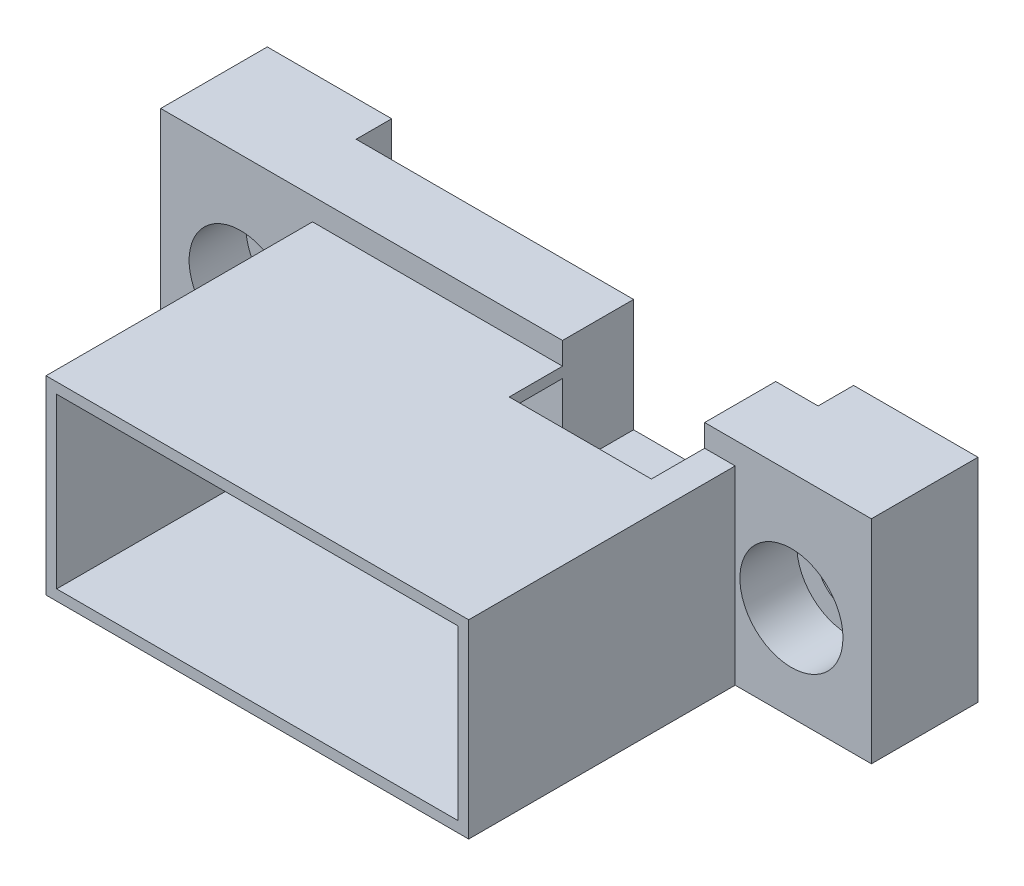
from build123d import *

# Parameters (mm, degrees)
SKETCH4_W               = 50.8
SKETCH4_H               = 16.764
BOSS_EXTRUDE1_DEPTH     = 7.62
SKETCH5_R               = 0.8255
SKETCH5_W               = 10.16
SKETCH5_H               = 5.08
CUT_EXTRUDE1_DEPTH      = 7.62
SKETCH6_R               = 3.683
SKETCH6_R_2             = 2.2225
CUT_EXTRUDE2_DEPTH      = 4.064
SKETCH6_2_R             = 2.2225
CUT_EXTRUDE3_DEPTH      = 7.62
SKETCH7_W               = 33.02
SKETCH7_H               = 5.08
CUT_EXTRUDE4_DEPTH      = 1
CUT_EXTRUDE4_DEPTH_BACK = 17.764
SKETCH8_W               = 10.16
SKETCH8_H               = 2.54
CUT_EXTRUDE5_DEPTH      = 4.064
SKETCH9_W               = 30.2133
SKETCH9_H               = 13.5763
SKETCH9_W_2             = 28.6893
SKETCH9_H_2             = 12.0523
BOSS_EXTRUDE4_DEPTH     = 19.05
SKETCH12_W              = 10.16
SKETCH12_H              = 2.99085
CUT_EXTRUDE6_DEPTH      = 6.35
SKETCH13_W              = 50.8
SKETCH13_H              = 1.59385
CUT_EXTRUDE7_DEPTH      = 20.05
CUT_EXTRUDE7_DEPTH_BACK = 8.62


with BuildPart() as part:
    # Sketch4 → Boss-Extrude1 (new body)
    with BuildSketch(Plane.XY):
        Rectangle(SKETCH4_W, SKETCH4_H)
    extrude(amount=BOSS_EXTRUDE1_DEPTH)

    # Sketch5 → Cut-Extrude1 (cut)
    with BuildSketch(Plane.XY.offset(7.62)):
        with Locations((-11.24585, 3.48615)):
            Circle(SKETCH5_R)
        with Locations((12.36345, -3.48615)):
            Circle(SKETCH5_R)
        with Locations((8.40105, 2.85115)):
            Rectangle(SKETCH5_W, SKETCH5_H)
    extrude(amount=-CUT_EXTRUDE1_DEPTH, mode=Mode.SUBTRACT)

    # Sketch6 → Cut-Extrude2 (cut)
    with BuildSketch(Plane.XY.offset(7.62)):
        with Locations((-19.685, 0)):
            Circle(SKETCH6_R)
        with Locations((-19.685, 0)):
            Circle(SKETCH6_R_2, mode=Mode.SUBTRACT)
        with Locations((19.685, 0)):
            Circle(SKETCH6_R)
        with Locations((19.685, 0)):
            Circle(SKETCH6_R_2, mode=Mode.SUBTRACT)
    extrude(amount=-CUT_EXTRUDE2_DEPTH, mode=Mode.SUBTRACT)

    # Sketch6_2 → Cut-Extrude3 (cut)
    with BuildSketch(Plane.XY.offset(7.62)):
        with Locations((-19.685, 0)):
            Circle(SKETCH6_2_R)
        with Locations((19.685, 0)):
            Circle(SKETCH6_2_R)
    extrude(amount=-CUT_EXTRUDE3_DEPTH, mode=Mode.SUBTRACT)

    # Sketch7 → Cut-Extrude4 (cut, two sides)
    with BuildSketch(Plane(origin=(0, 8.382, 0), x_dir=(1, 0, 0), z_dir=(0, 1, 0))) as cut_extrude4_sk:
        Rectangle(SKETCH7_W, SKETCH7_H)
    extrude(amount=CUT_EXTRUDE4_DEPTH, mode=Mode.SUBTRACT)
    extrude(cut_extrude4_sk.sketch, amount=-CUT_EXTRUDE4_DEPTH_BACK, mode=Mode.SUBTRACT)

    # Sketch8 → Cut-Extrude5 (cut)
    with BuildSketch(Plane.XZ.offset(-5.39115)):
        with Locations((8.40105, 3.81)):
            Rectangle(SKETCH8_W, SKETCH8_H)
    extrude(amount=-CUT_EXTRUDE5_DEPTH, mode=Mode.SUBTRACT)

    # Sketch9 → Boss-Extrude4 (add)
    with BuildSketch(Plane.XY.offset(7.62)):
        with Locations((0.5588, 0)):
            Rectangle(SKETCH9_W, SKETCH9_H)
        with Locations((0.5588, 0)):
            Rectangle(SKETCH9_W_2, SKETCH9_H_2, mode=Mode.SUBTRACT)
    extrude(amount=BOSS_EXTRUDE4_DEPTH)

    # Sketch12 → Cut-Extrude6 (cut)
    with BuildSketch(Plane(origin=(0, 0, 5.08), x_dir=(-1, 0, 0), z_dir=(0, 0, -1))):
        with Locations((-8.40105, 6.886575)):
            Rectangle(SKETCH12_W, SKETCH12_H)
    extrude(amount=-CUT_EXTRUDE6_DEPTH, mode=Mode.SUBTRACT)

    # Sketch13 → Cut-Extrude7 (cut, two sides)
    with BuildSketch(Plane.XY.offset(7.62)) as cut_extrude7_sk:
        with Locations((0, -7.585075)):
            Rectangle(SKETCH13_W, SKETCH13_H)
    extrude(amount=CUT_EXTRUDE7_DEPTH, mode=Mode.SUBTRACT)
    extrude(cut_extrude7_sk.sketch, amount=-CUT_EXTRUDE7_DEPTH_BACK, mode=Mode.SUBTRACT)


solid = part.part
